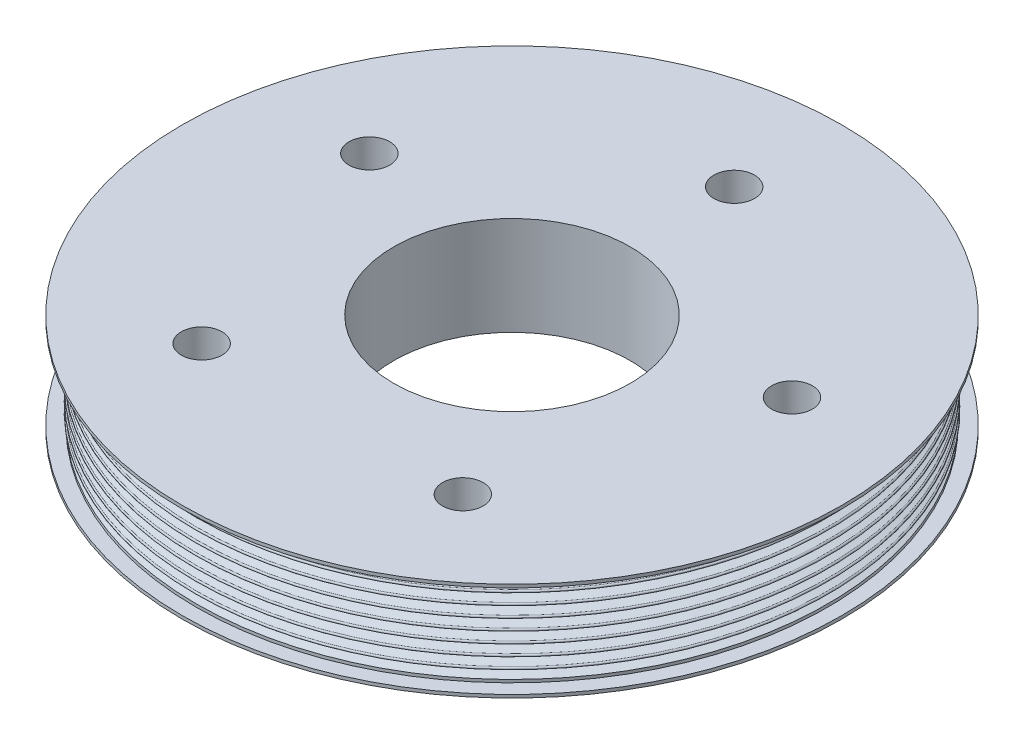
from build123d import *

# Parameters (mm, degrees)
SKETCH2_R               = 38.1
CUT_EXTRUDE1_DEPTH      = 32.74492
F_1_2_CLEARANCE_HOLE1_D = 13.09624
CIRPATTERN1_COUNT       = 5


with BuildPart() as part:
    # Sketch1 → Revolve1 (revolve)
    with BuildSketch(Plane.XY):
        with BuildLine():
            Line((101.6, 13.90396), (101.6, 14.85646))
            Line((101.6, 14.85646), (106.172, 14.85646))
            Line((106.172, 14.85646), (106.172, 15.87246))
            Line((106.172, 15.87246), (101.6, 15.87246))
            Line((101.6, 15.87246), (0, 15.87246))
            Line((0, 15.87246), (0, -15.87246))
            Line((0, -15.87246), (101.6, -15.87246))
            Line((101.6, -15.87246), (106.172, -15.87246))
            Line((106.172, -15.87246), (106.172, -14.85646))
            Line((106.172, -14.85646), (101.6, -14.85646))
            Line((101.6, -14.85646), (101.6, -13.90396))
            Line((101.6, -13.90396), (98.787627164, -12.88034))
            ThreePointArc((98.787627164, -12.88034), (98.406627164, -12.49934), (98.787627164, -12.11834))
            Line((98.787627164, -12.11834), (101.6, -11.09472))
            ThreePointArc((101.6, -11.09472), (101.981, -10.71372), (101.6, -10.33272))
            Line((101.6, -10.33272), (98.787627164, -9.3091))
            ThreePointArc((98.787627164, -9.3091), (98.406627164, -8.9281), (98.787627164, -8.5471))
            Line((98.787627164, -8.5471), (101.6, -7.52348))
            ThreePointArc((101.6, -7.52348), (101.981, -7.14248), (101.6, -6.76148))
            Line((101.6, -6.76148), (98.787627164, -5.73786))
            ThreePointArc((98.787627164, -5.73786), (98.406627164, -5.35686), (98.787627164, -4.97586))
            Line((98.787627164, -4.97586), (101.6, -3.95224))
            ThreePointArc((101.6, -3.95224), (101.981, -3.57124), (101.6, -3.19024))
            Line((101.6, -3.19024), (98.787627164, -2.16662))
            ThreePointArc((98.787627164, -2.16662), (98.406627164, -1.78562), (98.787627164, -1.40462))
            Line((98.787627164, -1.40462), (101.6, -0.381))
            ThreePointArc((101.6, -0.381), (101.981, 0), (101.6, 0.381))
            Line((101.6, 0.381), (98.787627164, 1.40462))
            ThreePointArc((98.787627164, 1.40462), (98.406627164, 1.78562), (98.787627164, 2.16662))
            Line((98.787627164, 2.16662), (101.6, 3.19024))
            ThreePointArc((101.6, 3.19024), (101.981, 3.57124), (101.6, 3.95224))
            Line((101.6, 3.95224), (98.787627164, 4.97586))
            ThreePointArc((98.787627164, 4.97586), (98.406627164, 5.35686), (98.787627164, 5.73786))
            Line((98.787627164, 5.73786), (101.6, 6.76148))
            ThreePointArc((101.6, 6.76148), (101.981, 7.14248), (101.6, 7.52348))
            Line((101.6, 7.52348), (98.787627164, 8.5471))
            ThreePointArc((98.787627164, 8.5471), (98.406627164, 8.9281), (98.787627164, 9.3091))
            Line((98.787627164, 9.3091), (101.6, 10.33272))
            ThreePointArc((101.6, 10.33272), (101.981, 10.71372), (101.6, 11.09472))
            Line((101.6, 11.09472), (98.787627164, 12.11834))
            ThreePointArc((98.787627164, 12.11834), (98.406627164, 12.49934), (98.787627164, 12.88034))
            Line((98.787627164, 12.88034), (101.6, 13.90396))
        make_face()
    revolve(axis=Axis((0, 15.87246, 0), (0, -1, 0)))

    # Sketch2 → Cut-Extrude1 (cut, through all)
    with BuildSketch(Plane(origin=(0, 15.87246, 0), x_dir=(1, 0, 0), z_dir=(0, 1, 0))):
        Circle(SKETCH2_R)
    extrude(amount=-CUT_EXTRUDE1_DEPTH, mode=Mode.SUBTRACT)

    # 1/2 Clearance Hole1 (through all)
    with Locations(Plane.XZ.offset(15.87246)):
        with Locations((0, -71.5518)):
            f_1_2_clearance_hole1 = Hole(F_1_2_CLEARANCE_HOLE1_D / 2)

    # CirPattern1: 1/2 Clearance Hole1 ×5 about axis
    cirpattern1_axis = Axis((0, 0, 0), (0, 1, 0))
    for i in range(1, CIRPATTERN1_COUNT):
        add(f_1_2_clearance_hole1.rotate(cirpattern1_axis, i * 360 / CIRPATTERN1_COUNT), mode=Mode.SUBTRACT)


solid = part.part
